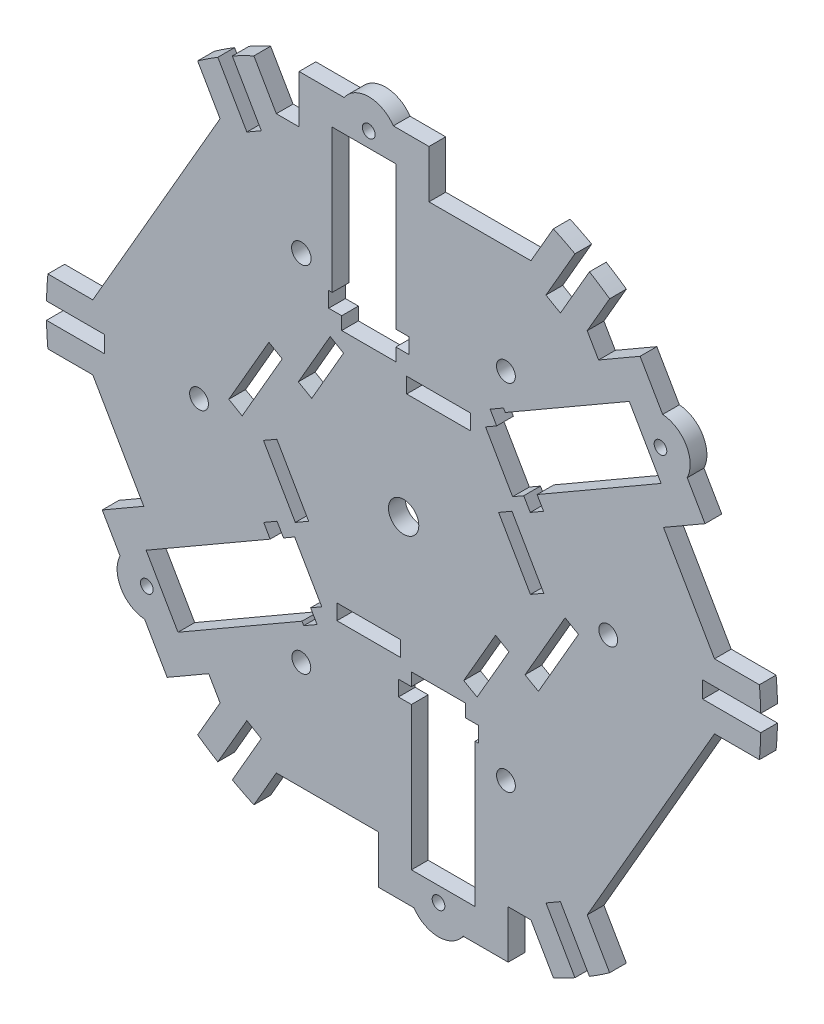
from build123d import *

# Parameters (mm, degrees)
MODEL_R             = 2.9
MODEL_R_2           = 3
MODEL_R_3           = 1.95
MODEL_R_4           = 4.665
MODEL_W             = 19.6
MODEL_H             = 4.75
BOSS_EXTRUDE1_DEPTH = 5.15


with BuildPart() as part:
    # Model → Boss-Extrude1 (new body)
    with BuildSketch(Plane.XY):
        with BuildLine():
            Line((43.819984585, 81.048439688), (48.280015415, 78.473439688))
            Line((48.280015415, 78.473439688), (57.214943747, 93.949189523))
            ThreePointArc((57.214943747, 93.949189523), (60.358438208, 91.961181686), (63.432925851, 89.868036131))
            Line((63.432925851, 89.868036131), (56.520818931, 77.895915758))
            Line((56.520818931, 77.895915758), (60.020818931, 71.833737931))
            Line((60.020818931, 71.833737931), (72.810336239, 79.217769192))
            Line((72.810336239, 79.217769192), (79.758802159, 67.182673184))
            ThreePointArc((79.758802159, 67.182673184), (87.004437854, 62.632864027), (87.321870319, 54.083054869))
            Line((87.321870319, 54.083054869), (92.810336239, 44.57675304))
            Line((92.810336239, 44.57675304), (80.020818931, 37.19272178))
            Line((80.020818931, 37.19272178), (95.720818931, 9.999524101))
            Line((95.720818931, 9.999524101), (109.544554943, 9.999524101))
            ThreePointArc((109.544554943, 9.999524101), (109.819966834, 6.290857214), (109.969856665, 2.575))
            Line((109.969856665, 2.575), (92.1, 2.575))
            Line((92.1, 2.575), (92.1, -2.575))
            Line((92.1, -2.575), (109.969856665, -2.575))
            ThreePointArc((109.969856665, -2.575), (109.819947856, -6.291188516), (109.544494609, -10.000185045))
            Line((109.544494609, -10.000185045), (95.720280769, -10.000185045))
            Line((95.720280769, -10.000185045), (56.520280769, -77.896576702))
            Line((56.520280769, -77.896576702), (63.432272389, -89.86849737))
            ThreePointArc((63.432272389, -89.86849737), (60.358103868, -91.961401128), (57.214943747, -93.949189523))
            Line((57.214943747, -93.949189523), (48.280015415, -78.473439688))
            Line((48.280015415, -78.473439688), (43.819984585, -81.048439688))
            Line((43.819984585, -81.048439688), (52.754912918, -96.524189523))
            ThreePointArc((52.754912918, -96.524189523), (49.461727838, -98.252417168), (46.112001713, -99.868329805))
            Line((46.112001713, -99.868329805), (39.2, -87.896391657))
            Line((39.2, -87.896391657), (32.2, -87.896391657))
            Line((32.2, -87.896391657), (32.2, -102.664454178))
            Line((32.2, -102.664454178), (18.303068161, -102.664454178))
            ThreePointArc((18.303068161, -102.664454178), (10.74, -106.664454178), (3.17693184, -102.664454178))
            Line((3.17693184, -102.664454178), (-7.8, -102.664454178))
            Line((-7.8, -102.664454178), (-7.8, -87.896391657))
            Line((-7.8, -87.896391657), (-39.2, -87.896391657))
            Line((-39.2, -87.896391657), (-46.112001713, -99.868329805))
            ThreePointArc((-46.112001713, -99.868329805), (-49.461727838, -98.252417168), (-52.754912918, -96.524189523))
            Line((-52.754912918, -96.524189523), (-43.819984585, -81.048439689))
            Line((-43.819984585, -81.048439689), (-48.280015415, -78.473439689))
            Line((-48.280015415, -78.473439689), (-57.214943747, -93.949189523))
            ThreePointArc((-57.214943747, -93.949189523), (-60.358012455, -91.961461126), (-63.432093724, -89.868623478))
            Line((-63.432093724, -89.868623478), (-56.52019722, -77.896867556))
            Line((-56.52019722, -77.896867556), (-60.02019722, -71.834689729))
            Line((-60.02019722, -71.834689729), (-72.809714528, -79.218720989))
            Line((-72.809714528, -79.218720989), (-79.758180447, -67.183624982))
            ThreePointArc((-79.758180447, -67.183624982), (-87.003816143, -62.633815824), (-87.321248608, -54.084006667))
            Line((-87.321248608, -54.084006667), (-92.809714528, -44.577704838))
            Line((-92.809714528, -44.577704838), (-80.02019722, -37.193673578))
            Line((-80.02019722, -37.193673578), (-95.72019722, -10.000475899))
            Line((-95.72019722, -10.000475899), (-109.544468057, -10.000475899))
            ThreePointArc((-109.544468057, -10.000475899), (-109.819939504, -6.291334309), (-109.969856665, -2.575))
            Line((-109.969856665, -2.575), (-92.1, -2.575))
            Line((-92.1, -2.575), (-92.1, 2.575))
            Line((-92.1, 2.575), (-109.969856665, 2.575))
            ThreePointArc((-109.969856665, 2.575), (-109.819958483, 6.291003006), (-109.544528393, 9.999814955))
            Line((-109.544528393, 9.999814955), (-95.720735382, 9.999814955))
            Line((-95.720735382, 9.999814955), (-56.520735382, 77.896206612))
            Line((-56.520735382, 77.896206612), (-63.432747187, 89.86816224))
            ThreePointArc((-63.432747187, 89.86816224), (-60.358346795, 91.961241684), (-57.214943747, 93.949189523))
            Line((-57.214943747, 93.949189523), (-48.280015415, 78.473439689))
            Line((-48.280015415, 78.473439689), (-43.819984585, 81.048439689))
            Line((-43.819984585, 81.048439689), (-52.754912918, 96.524189523))
            ThreePointArc((-52.754912918, 96.524189523), (-49.461727838, 98.252417168), (-46.112001713, 99.868329805))
            Line((-46.112001713, 99.868329805), (-39.2, 87.896391657))
            Line((-39.2, 87.896391657), (-32.2, 87.896391657))
            Line((-32.2, 87.896391657), (-32.2, 102.664454178))
            Line((-32.2, 102.664454178), (-18.30306816, 102.664454178))
            ThreePointArc((-18.30306816, 102.664454178), (-10.74, 106.664454178), (-3.176931839, 102.664454178))
            Line((-3.176931839, 102.664454178), (7.8, 102.664454178))
            Line((7.8, 102.664454178), (7.8, 87.896391657))
            Line((7.8, 87.896391657), (39.2, 87.896391657))
            Line((39.2, 87.896391657), (46.112001713, 99.868329805))
            ThreePointArc((46.112001713, 99.868329805), (49.461727838, 98.252417168), (52.754912918, 96.524189523))
            Line((52.754912918, 96.524189523), (43.819984585, 81.048439688))
        make_face()
        with Locations((-63, 0)):
            Circle(MODEL_R, mode=Mode.SUBTRACT)
        with Locations((-31.5, -54.559600438)):
            Circle(MODEL_R, mode=Mode.SUBTRACT)
        with Locations((31.5, -54.559600438)):
            Circle(MODEL_R, mode=Mode.SUBTRACT)
        with Locations((63, 0)):
            Circle(MODEL_R, mode=Mode.SUBTRACT)
        with Locations((31.5, 54.559600438)):
            Circle(MODEL_R, mode=Mode.SUBTRACT)
        with Locations((-31.5, 54.559600438)):
            Circle(MODEL_R_2, mode=Mode.SUBTRACT)
        with Locations((-79.079683698, -58.058815824)):
            Circle(MODEL_R_3, mode=Mode.SUBTRACT)
        with Locations((79.08030541, 58.057864027)):
            Circle(MODEL_R_3, mode=Mode.SUBTRACT)
        Circle(MODEL_R_4, mode=Mode.SUBTRACT)
        with Locations((-10.74, 97.514454178)):
            Circle(MODEL_R_3, mode=Mode.SUBTRACT)
        with Locations((10.74, -97.514454178)):
            Circle(MODEL_R_3, mode=Mode.SUBTRACT)
        Polygon((33.357314709, 18.17343612), (29.243694041, 15.79843612), (39.043694041, -1.175661794), (43.157314709, 1.199338206), align=None, mode=Mode.SUBTRACT)
        Polygon((32.417314709, -19.80156388), (28.303694041, -17.42656388), (18.503694041, -34.400661794), (22.617314709, -36.775661794), align=None, mode=Mode.SUBTRACT)
        with Locations((-10.74, -35.6)):
            Rectangle(MODEL_W, MODEL_H, mode=Mode.SUBTRACT)
        Polygon((-33.357314709, -18.17343612), (-29.243694041, -15.79843612), (-39.043694041, 1.175661794), (-43.157314709, -1.199338206), align=None, mode=Mode.SUBTRACT)
        Polygon((-32.417314709, 19.80156388), (-28.303694041, 17.42656388), (-18.503694041, 34.400661794), (-22.617314709, 36.775661794), align=None, mode=Mode.SUBTRACT)
        Polygon((36.982871141, 24.122696529), (38.982587357, 20.659086443), (43.096208025, 23.034086443), (41.096491809, 26.497696529), (79.288239187, 48.547712159), (69.488239187, 65.521810073), (31.296521386, 43.47181152), (30.75621053, 44.407594854), (26.642587357, 42.032593408), (28.642871141, 38.568000264), (25.222097867, 36.593015894), (33.562097867, 22.147712159), align=None, mode=Mode.SUBTRACT)
        Polygon((37.382587357, -23.430367735), (41.496208025, -25.805367735), (53.836208025, -4.431860769), (49.722587357, -2.056860769), align=None, mode=Mode.SUBTRACT)
        Polygon((2.4, -44.089454178), (-1.6, -44.089454178), (-1.6, -48.839454177), (2.4, -48.839454177), (2.4, -92.939454178), (22, -92.939454178), (22, -48.839454177), (23.08, -48.839454177), (23.08, -44.089454178), (19.08, -44.089454178), (19.08, -40.139454177), (2.4, -40.139454177), align=None, mode=Mode.SUBTRACT)
        Polygon((-36.982303573, -24.123679586), (-38.982587357, -20.659086443), (-43.096208025, -23.034086443), (-41.095924241, -26.498679586), (-79.287617476, -48.548663957), (-69.487617476, -65.522761871), (-31.295924241, -43.472777501), (-30.756208025, -44.407593408), (-26.642587357, -42.032593408), (-28.642303573, -38.568983322), (-25.221476156, -36.593967692), (-33.561476156, -22.148663957), align=None, mode=Mode.SUBTRACT)
        Polygon((-37.382587357, 23.430367735), (-41.496208025, 25.805367735), (-53.836208025, 4.431860769), (-49.722587357, 2.056860769), align=None, mode=Mode.SUBTRACT)
        with Locations((10.74, 35.6)):
            Rectangle(MODEL_W, MODEL_H, mode=Mode.SUBTRACT)
        Polygon((-2.4, 44.089454178), (1.6, 44.089454178), (1.6, 48.839454177), (-2.4, 48.839454177), (-2.4, 92.939454178), (-22, 92.939454178), (-22, 48.839454177), (-23.08, 48.839454177), (-23.08, 44.089454178), (-19.08, 44.089454178), (-19.08, 40.139454177), (-2.4, 40.139454177), align=None, mode=Mode.SUBTRACT)
    extrude(amount=BOSS_EXTRUDE1_DEPTH)


solid = part.part
